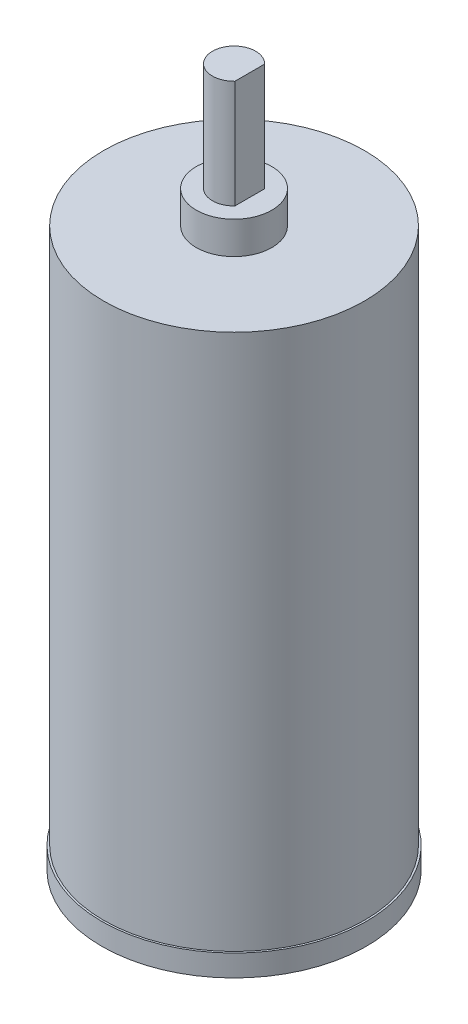
from build123d import *

# Parameters (mm, degrees)
SKETCH_1_R      = 12.25
EXTRUDE_1_DEPTH = 2
SKETCH_2_R      = 12.075
EXTRUDE_2_DEPTH = 51.65
SKETCH_3_R      = 3.5
EXTRUDE_3_DEPTH = 3
EXTRUDE_4_DEPTH = 10


with BuildPart() as part:
    # Эскиз1 → Бобышка-Вытянуть1 (new body)
    with BuildSketch(Plane(origin=(0, 0, 0), x_dir=(1, 0, 0), z_dir=(0, 1, 0))):
        Circle(SKETCH_1_R)
    extrude(amount=EXTRUDE_1_DEPTH)

    # Эскиз2 → Бобышка-Вытянуть2 (add)
    with BuildSketch(Plane(origin=(0, 0, 0), x_dir=(1, 0, 0), z_dir=(0, 1, 0))):
        Circle(SKETCH_2_R)
    extrude(amount=EXTRUDE_2_DEPTH)

    # Эскиз3 → Бобышка-Вытянуть3 (add)
    with BuildSketch(Plane(origin=(0, 51.65, 0), x_dir=(1, 0, 0), z_dir=(0, 1, 0))):
        Circle(SKETCH_3_R)
    extrude(amount=EXTRUDE_3_DEPTH)

    # Эскиз4 → Бобышка-Вытянуть4 (add)
    with BuildSketch(Plane(origin=(0, 54.65, 0), x_dir=(1, 0, 0), z_dir=(0, 1, 0))):
        with BuildLine():
            Line((1.45, 0), (1.45, 1.377497731))
            ThreePointArc((1.45, 1.377497731), (-2, 0), (1.45, -1.377497731))
            Line((1.45, -1.377497731), (1.45, 0))
        make_face()
    extrude(amount=EXTRUDE_4_DEPTH)


solid = part.part
